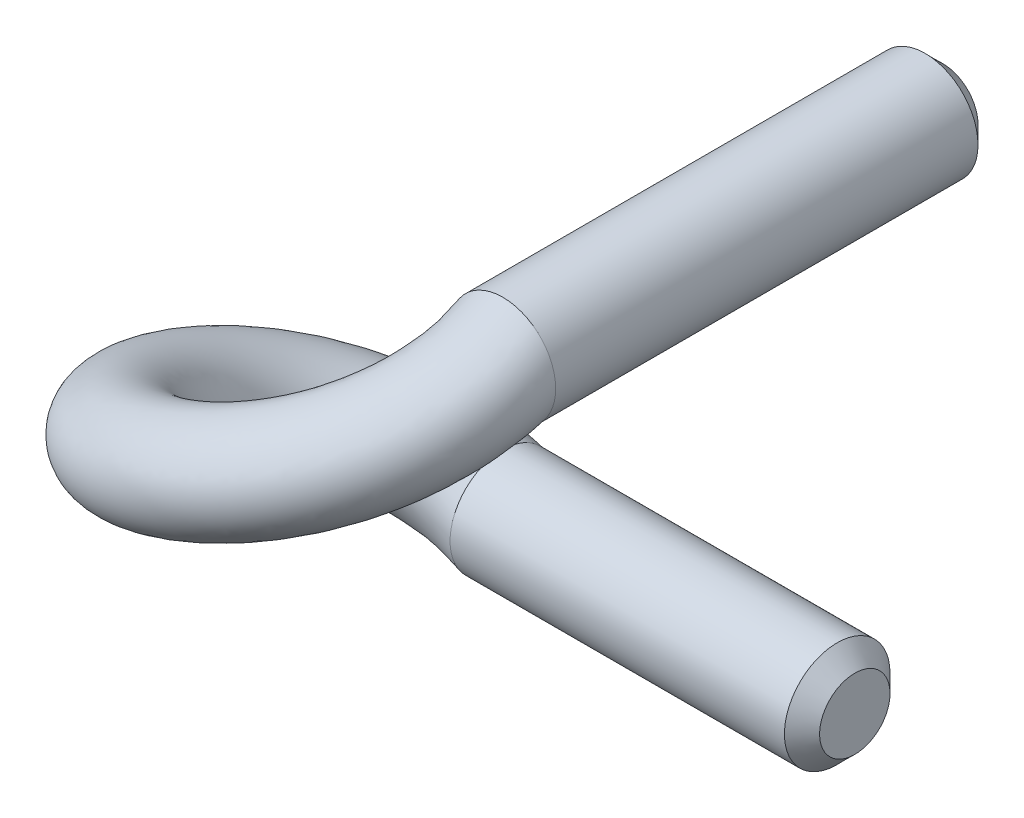
from build123d import *

# Parameters (mm, degrees)
SKIZZE1_R                       = 3
AUFSATZ_LINEAR_AUSTRAGEN1_DEPTH = 25
AUSTRAGUNG1_PITCH               = 22
AUSTRAGUNG1_HEIGHT              = 16.5
AUSTRAGUNG1_RADIUS              = 9
AUSTRAGUNG1_START_ANGLE         = 90
SKIZZE3_R                       = 3
SKIZZE4_R                       = 3
AUFSATZ_LINEAR_AUSTRAGEN2_DEPTH = 20
FASE1_SIZE                      = 1


with BuildPart() as part:
    # Skizze1 → Aufsatz-Linear austragen1 (new body)
    with BuildSketch(Plane.XY):
        Circle(SKIZZE1_R)
    extrude(amount=AUFSATZ_LINEAR_AUSTRAGEN1_DEPTH)

    # Austragung1: sweep along a helix
    with BuildLine() as austragung1_path:
        add(Helix(AUSTRAGUNG1_PITCH, AUSTRAGUNG1_HEIGHT, AUSTRAGUNG1_RADIUS, center=(-9, 0, 25), direction=(0, -1, 0), mode=Mode.PRIVATE).rotate(Axis((-9, 0, 25), (0, -1, 0)), AUSTRAGUNG1_START_ANGLE))
    # Skizze3 → Austragung1 (sweep)
    with BuildSketch(Plane.XY.offset(25)):
        Circle(SKIZZE3_R)
    sweep(path=austragung1_path.line, is_frenet=True)

    # Skizze4 → Aufsatz-Linear austragen2 (add)
    with BuildSketch(Plane(origin=(-9, 0, 0), x_dir=(0, 0, -1), z_dir=(1, 0, 0))):
        with Locations((-16, -16.5)):
            Circle(SKIZZE4_R)
    extrude(amount=AUFSATZ_LINEAR_AUSTRAGEN2_DEPTH)

    # Fase1
    fase1_edges = [part.edges().sort_by_distance(p)[0] for p in [
        (11, -16.5, 19),
        (-3, 0, 0),
    ]]
    chamfer(fase1_edges, length=FASE1_SIZE)


solid = part.part
